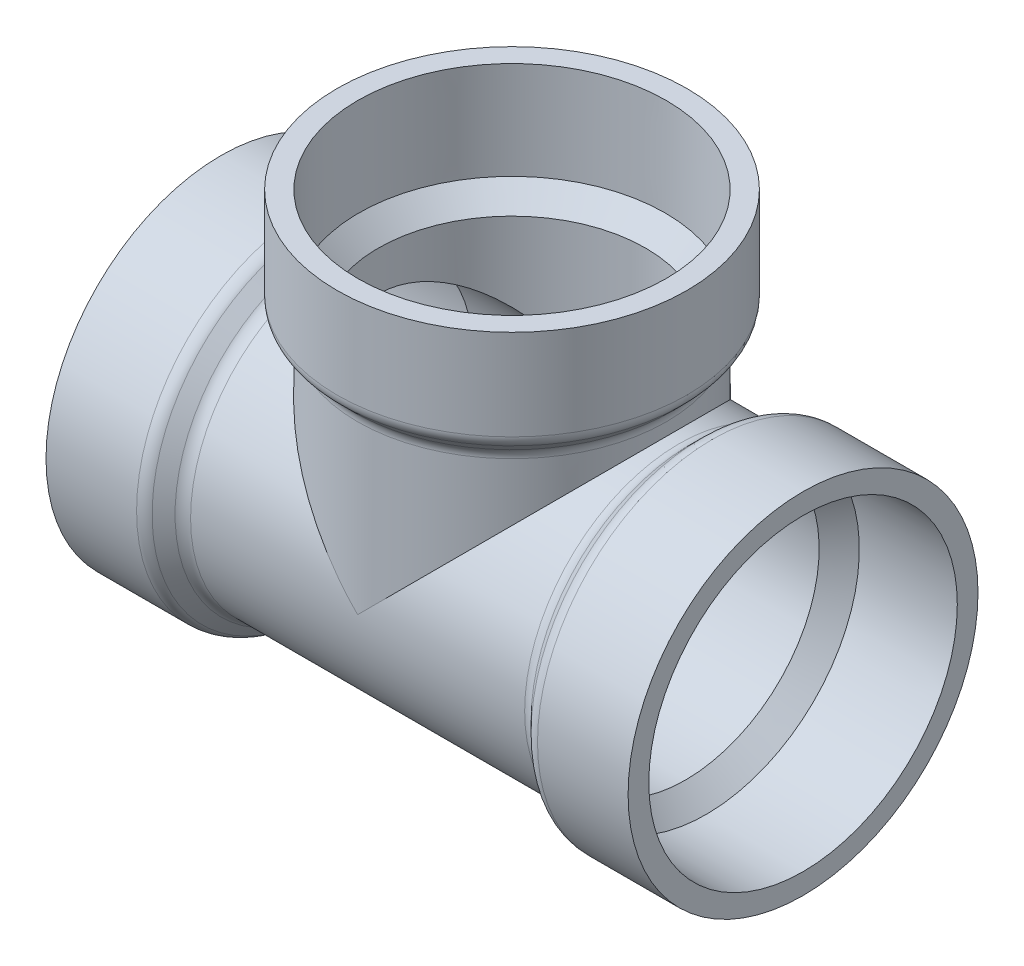
from build123d import *

# Parameters (mm, degrees)
SKETCH5_R           = 30.3149
BOSS_EXTRUDE1_DEPTH = 68.1228
SKETCH6_R           = 30.3149
BOSS_EXTRUDE2_DEPTH = 34.0614
FILLET1_R           = 3.048


with BuildPart() as part:
    # Sketch1 → Revolve1 (revolve)
    with BuildSketch(Plane.XY):
        Polygon((-38.1, -34.3535), (-34.0614, -30.3149), (-34.0614, -26.2509), (-38.1, -30.099), (-57.15, -30.2895), (-57.15, -34.3535), align=None)
    revolve(axis=Axis((-57.15, 0, 0), (1, 0, 0)))


with BuildPart() as body_2:
    # Mirror1: mirrored copy
    add(part.part.mirror(Plane(origin=(0, 0, 0), x_dir=(0, 0, 1), z_dir=(1, 0, 0))))


with BuildPart() as body_3:
    # Sketch2 → Revolve2 (revolve)
    with BuildSketch(Plane.XY):
        Polygon((30.2895, 57.15), (30.099, 38.1), (26.2509, 34.0614), (30.3149, 34.0614), (34.3535, 38.1), (34.3535, 57.15), align=None)
    revolve(axis=Axis((0, 0, 0), (0, 1, 0)))


with BuildPart() as part_1:
    add(part.part)

    add(body_2.part)  # Boss-Extrude1 merges body 2
    # Sketch5 → Boss-Extrude1 (add)
    with BuildSketch(Plane(origin=(-34.0614, 0, 0), x_dir=(0, 0, -1), z_dir=(1, 0, 0))):
        Circle(SKETCH5_R)
    extrude(amount=BOSS_EXTRUDE1_DEPTH)

    add(body_3.part)  # Boss-Extrude2 merges body 3
    # Sketch6 → Boss-Extrude2 (add)
    with BuildSketch(Plane.XZ.offset(-34.0614)):
        Circle(SKETCH6_R)
    extrude(amount=BOSS_EXTRUDE2_DEPTH)

    # Fillet1
    fillet1_edges = [part_1.edges().sort_by_distance(p)[0] for p in [
        (-34.0614, 21.435871361, 21.435871361),
        (34.0614, 21.435871361, 21.435871361),
        (-38.1, 34.3535, 0),
        (38.1, 34.3535, 0),
        (-30.3149, 34.0614, 0),
        (-34.3535, 38.1, 0),
    ]]
    fillet(fillet1_edges, radius=FILLET1_R)

    # Sketch7 → Cut-Revolve1 (revolve, cut)
    with BuildSketch(Plane.XY):
        Polygon((-57.15, 0), (57.15, 0), (57.15, 30.2895), (38.1, 30.099), (34.0614, 26.2509), (-34.0614, 26.2509), (-38.1, 30.099), (-57.15, 30.2895), align=None)
    revolve(axis=Axis((-57.15, 0, 0), (1, 0, 0)), mode=Mode.SUBTRACT)

    # Sketch8 → Cut-Revolve4 (revolve, cut)
    with BuildSketch(Plane.XY):
        Polygon((30.2895, 57.15), (30.099, 38.1), (26.2509, 34.0614), (26.2509, 0), (0, 0), (0, 57.15), align=None)
    revolve(axis=Axis((0, 0, 0), (0, 1, 0)), mode=Mode.SUBTRACT)


solid = part_1.part
